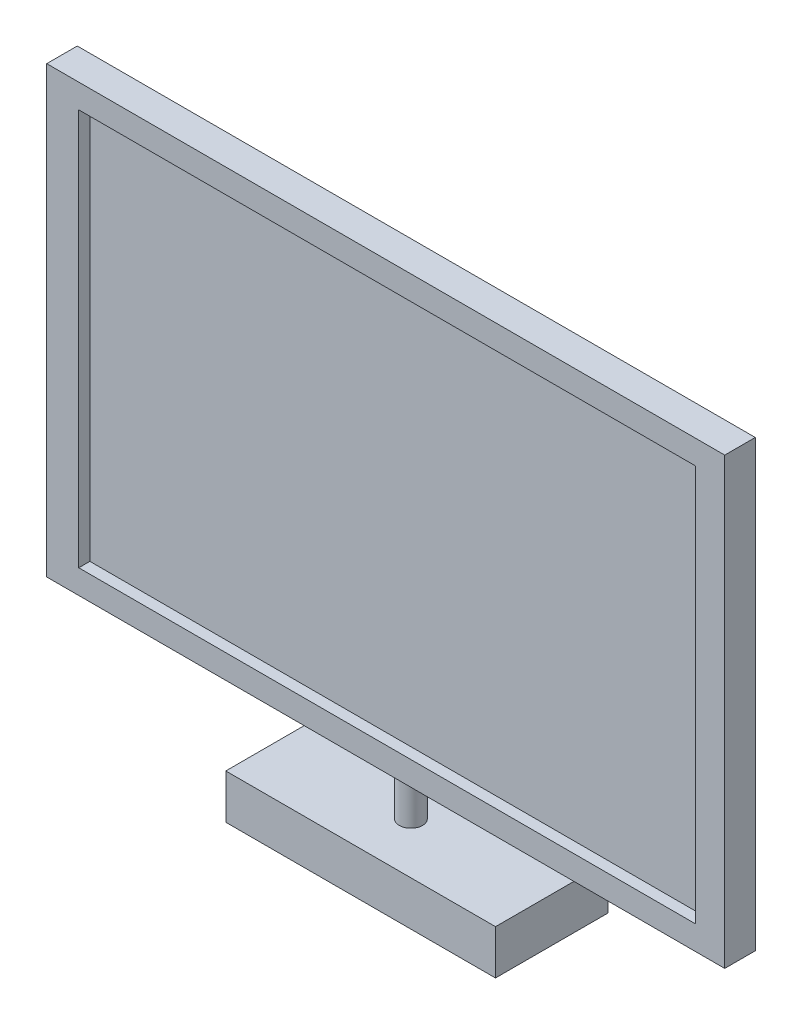
from build123d import *

# Parameters (mm, degrees)
CROQUIS1_W              = 24.727272727
CROQUIS1_H              = 360
SALIENTE_EXTRUIR1_DEPTH = 549
CROQUIS3_W              = 499.313479992
CROQUIS3_H              = 321.141187852
CORTAR_EXTRUIR1_DEPTH   = 9
CROQUIS4_R              = 9.403689311
SALIENTE_EXTRUIR2_DEPTH = 36
CROQUIS5_W              = 218.404745205
CROQUIS5_H              = 91.241456057
SALIENTE_EXTRUIR3_DEPTH = 36


with BuildPart() as part:
    # Croquis1 → Saliente-Extruir1 (new body)
    with BuildSketch(Plane(origin=(0, 0, 0), x_dir=(0, 0, -1), z_dir=(1, 0, 0))):
        with Locations((12.363636364, 180)):
            Rectangle(CROQUIS1_W, CROQUIS1_H)
    extrude(amount=SALIENTE_EXTRUIR1_DEPTH)

    # Croquis3 → Cortar-Extruir1 (cut)
    with BuildSketch(Plane.XY):
        with Locations((275.577654993, 180)):
            Rectangle(CROQUIS3_W, CROQUIS3_H)
    extrude(amount=-CORTAR_EXTRUIR1_DEPTH, mode=Mode.SUBTRACT)

    # Croquis4 → Saliente-Extruir2 (add)
    with BuildSketch(Plane.XZ):
        with Locations((280.998241646, -13.903750832)):
            Circle(CROQUIS4_R)
    extrude(amount=SALIENTE_EXTRUIR2_DEPTH)

    # Croquis5 → Saliente-Extruir3 (add)
    with BuildSketch(Plane.XZ.offset(36)):
        with Locations((281.684366619, -18.111129658)):
            Rectangle(CROQUIS5_W, CROQUIS5_H)
    extrude(amount=SALIENTE_EXTRUIR3_DEPTH)


solid = part.part
